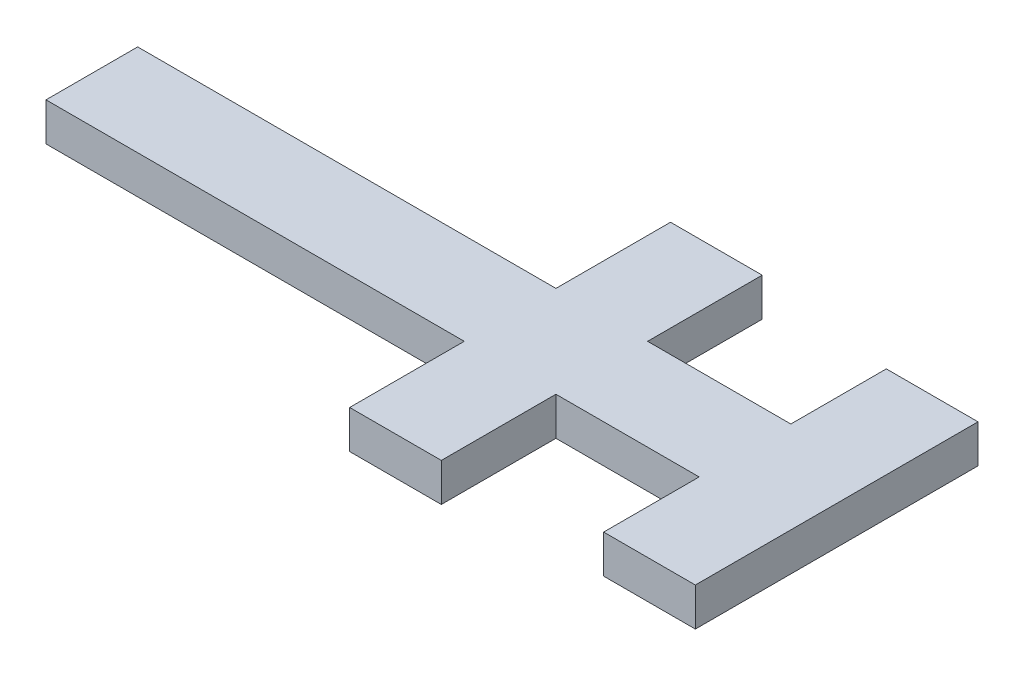
from build123d import *

# Parameters (mm, degrees)
SKETCH_3_W           = 10
SKETCH_3_H           = 35
SKETCH_3_W_2         = 20.75
SKETCH_3_H_2         = 10
SKETCH_3_W_3         = 29.75
SKETCH_3_W_4         = 25
EXTRUDE_1_DEPTH      = 1
EXTRUDE_2_DEPTH      = 4
EXTRUDE_2_DEPTH_BACK = 1
SKETCH_5_W           = 25
SKETCH_5_H           = 10
SKETCH_5_W_2         = 10
SKETCH_5_H_2         = 35
EXTRUDE_3_DEPTH      = 2


with BuildPart() as part:
    # 草图3 → 凸台-拉伸1 (new body)
    with BuildSketch(Plane(origin=(0, 0, 0), x_dir=(1, 0, 0), z_dir=(0, 1, 0))):
        with Locations((17.5, 0)):
            Rectangle(SKETCH_3_W, SKETCH_3_H)
        with Locations((2.125, 0)):
            Rectangle(SKETCH_3_W_2, SKETCH_3_H_2)
        Polygon((-8.25, -5), (-8.25, 5), (-8.25, 20), (-18.25, 20), (-18.25, 5), (-18.25, -5), (-18.25, -20), (-8.25, -20), align=None)
        with Locations((-33.125, 0)):
            Rectangle(SKETCH_3_W_3, SKETCH_3_H_2)
        with Locations((-60.5, 0)):
            Rectangle(SKETCH_3_W_4, SKETCH_3_H_2)
    extrude(amount=EXTRUDE_1_DEPTH)

    # 草图4 → 凸台-拉伸2 (add, two sides)
    with BuildSketch(Plane.XZ) as extrude_2_sk:
        Polygon((11.5, -18.5), (23.5, -18.5), (23.5, 18.5), (11.5, 18.5), (11.5, 6), (-7.25, 6), (-7.25, 21), (-19.25, 21), (-19.25, 6), (-74, 6), (-74, -6), (-19.25, -6), (-19.25, -21), (-7.25, -21), (-7.25, -6), (11.5, -6), align=None)
        Polygon((12.5, -17.5), (22.5, -17.5), (22.5, 17.5), (12.5, 17.5), (12.5, 5), (-8.25, 5), (-8.25, 20), (-18.25, 20), (-18.25, 5), (-73, 5), (-73, -5), (-18.25, -5), (-18.25, -20), (-8.25, -20), (-8.25, -5), (12.5, -5), align=None, mode=Mode.SUBTRACT)
    extrude(amount=EXTRUDE_2_DEPTH)
    extrude(extrude_2_sk.sketch, amount=-EXTRUDE_2_DEPTH_BACK)

    # 草图5 → 凸台-拉伸3 (add)
    with BuildSketch(Plane.XZ):
        Polygon((-18.25, 20), (-18.25, 5), (-14, 5), (-14, -5), (-18.25, -5), (-18.25, -20), (-8.25, -20), (-8.25, -5), (-12.5, -5), (-12.5, 5), (-8.25, 5), (-8.25, 20), align=None)
        with Locations((-60.5, 0)):
            Rectangle(SKETCH_5_W, SKETCH_5_H)
        with Locations((17.5, 0)):
            Rectangle(SKETCH_5_W_2, SKETCH_5_H_2)
    extrude(amount=EXTRUDE_3_DEPTH)


solid = part.part
